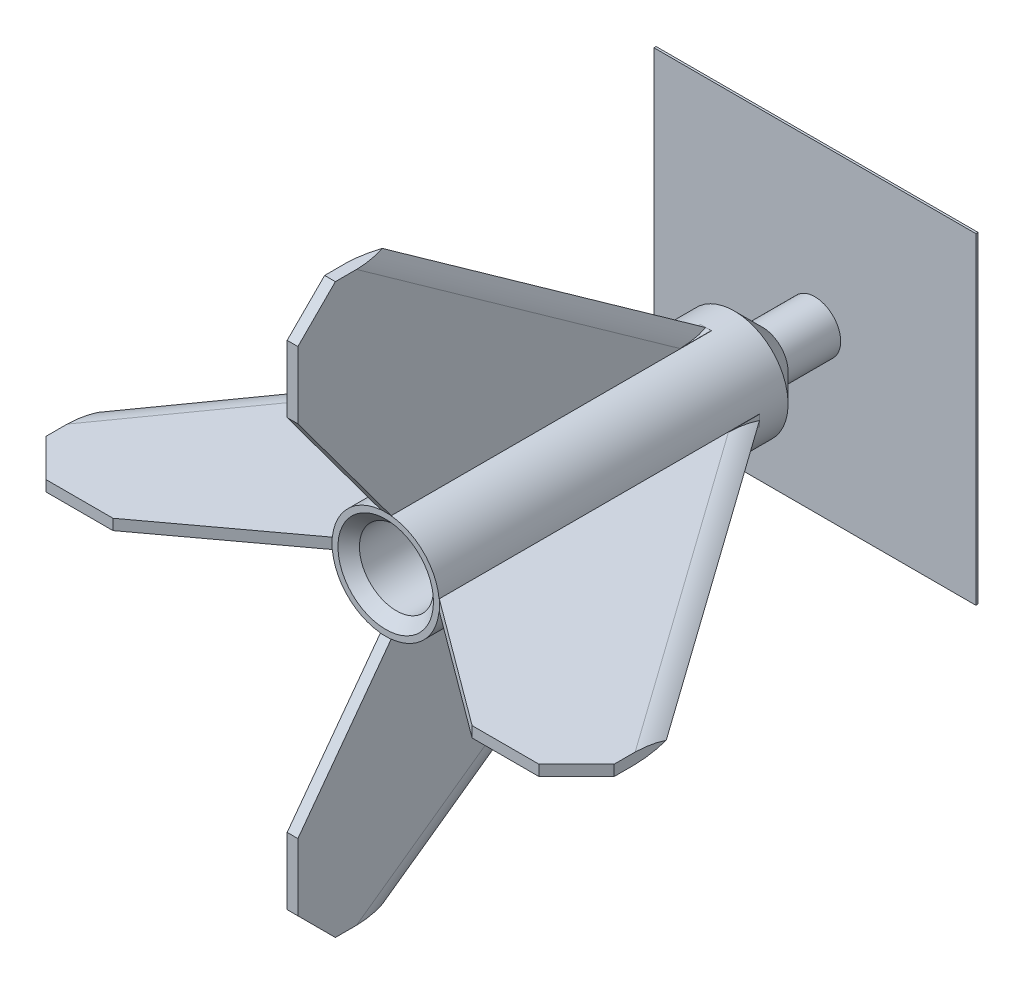
from build123d import *

# Parameters (mm, degrees)
SKETCH2_R           = 8.763
CUT_EXTRUDE1_DEPTH  = 69.85
BOSS_EXTRUDE1_DEPTH = 1.27
CIRPATTERN1_COUNT   = 4
CHAMFER1_SIZE       = 2.54
SKETCH10_W          = 76.2
SKETCH10_H          = 76.2
BOSS_EXTRUDE4_DEPTH = 0.508


with BuildPart() as part:
    # Sketch1 → Revolve1 (revolve)
    with BuildSketch(Plane(origin=(0, 0, 0), x_dir=(1, 0, 0), z_dir=(0, 1, 0))):
        Polygon((0, 101.6), (-6.096, 101.6), (-6.096, 89.154), (-12.7, 82.55), (-12.7, 0), (0, 0), align=None)
    revolve(axis=Axis((0, 0, -101.6), (0, 0, 1)))

    # Sketch2 → Cut-Extrude1 (cut)
    with BuildSketch(Plane.XY):
        Circle(SKETCH2_R)
    extrude(amount=-CUT_EXTRUDE1_DEPTH, mode=Mode.SUBTRACT)

    # Sketch3 → Boss-Extrude1 (add, symmetric)
    with BuildSketch(Plane(origin=(0, 0, 0), x_dir=(1, 0, 0), z_dir=(0, 1, 0))):
        Polygon((-10.365704675, 0), (-12.7, 0), (-42.511621146, -22.056416192), (-58.358338046, -22.056416192), (-67.228379248, -13.18637499), (-67.228379248, -0.821064085), (-10.365704675, 79.063680635), align=None)
    boss_extrude1 = extrude(amount=BOSS_EXTRUDE1_DEPTH, both=True)

    # Cut-Sweep1: sweep along a path in Sketch4
    with BuildLine(Plane(origin=(-44.232547401, 0, -31.485122188), x_dir=(-0.579901297, 0, 0.814686741), z_dir=(-0.814686741, 0, -0.579901297))) as cut_sweep1_path:
        Line((39.654734318, 0), (-54.375714603, 0))
    # Sketch5 → Cut-Sweep1 (sweep, cut)
    with BuildSketch(Plane.ZY.offset(67.228379248)):
        with BuildLine():
            Line((8.176199828, -4.186863215), (8.176199828, -1.27))
            ThreePointArc((8.176199828, -1.27), (4.450761752, -0.912237677), (0.821064085, 0))
            ThreePointArc((0.821064085, 0), (4.450761752, 0.912237677), (8.176199828, 1.27))
            Line((8.176199828, 1.27), (8.176199828, 4.131781822))
            Line((8.176199828, 4.131781822), (-5.582166947, 4.131781822))
            Line((-5.582166947, 4.131781822), (-5.582166947, -4.186863215))
            Line((-5.582166947, -4.186863215), (8.176199828, -4.186863215))
        make_face()
    cut_sweep1 = sweep(path=cut_sweep1_path.line, mode=Mode.SUBTRACT)

    # CirPattern1: Boss-Extrude1, Cut-Sweep1 ×4 about axis
    cirpattern1_axis = Axis((0, 0, 38.786024747), (0, 0, -1))
    add([boss_extrude1.rotate(cirpattern1_axis, i * 360 / CIRPATTERN1_COUNT) for i in range(1, CIRPATTERN1_COUNT)])
    add([cut_sweep1.rotate(cirpattern1_axis, i * 360 / CIRPATTERN1_COUNT) for i in range(1, CIRPATTERN1_COUNT)], mode=Mode.SUBTRACT)

    # Sketch6 → Cut-Revolve1 (revolve, cut)
    with BuildSketch(Plane(origin=(0, 0, 0), x_dir=(1, 0, 0), z_dir=(0, 1, 0))):
        Polygon((-8.763, 69.85), (0, 85.027961227), (0, 69.85), align=None)
    revolve(axis=Axis((0, 0, -85.027961227), (0, 0, 1)), mode=Mode.SUBTRACT)

    # Chamfer1
    chamfer1_edges = [part.edges().sort_by_distance(p)[0] for p in [
        (-8.763, 0, 0),
    ]]
    chamfer(chamfer1_edges, length=CHAMFER1_SIZE)

    # Sketch10 → Boss-Extrude4 (add)
    with BuildSketch(Plane(origin=(0, 0, -101.6), x_dir=(-1, 0, 0), z_dir=(0, 0, -1))):
        Rectangle(SKETCH10_W, SKETCH10_H)
    extrude(amount=BOSS_EXTRUDE4_DEPTH)


solid = part.part
